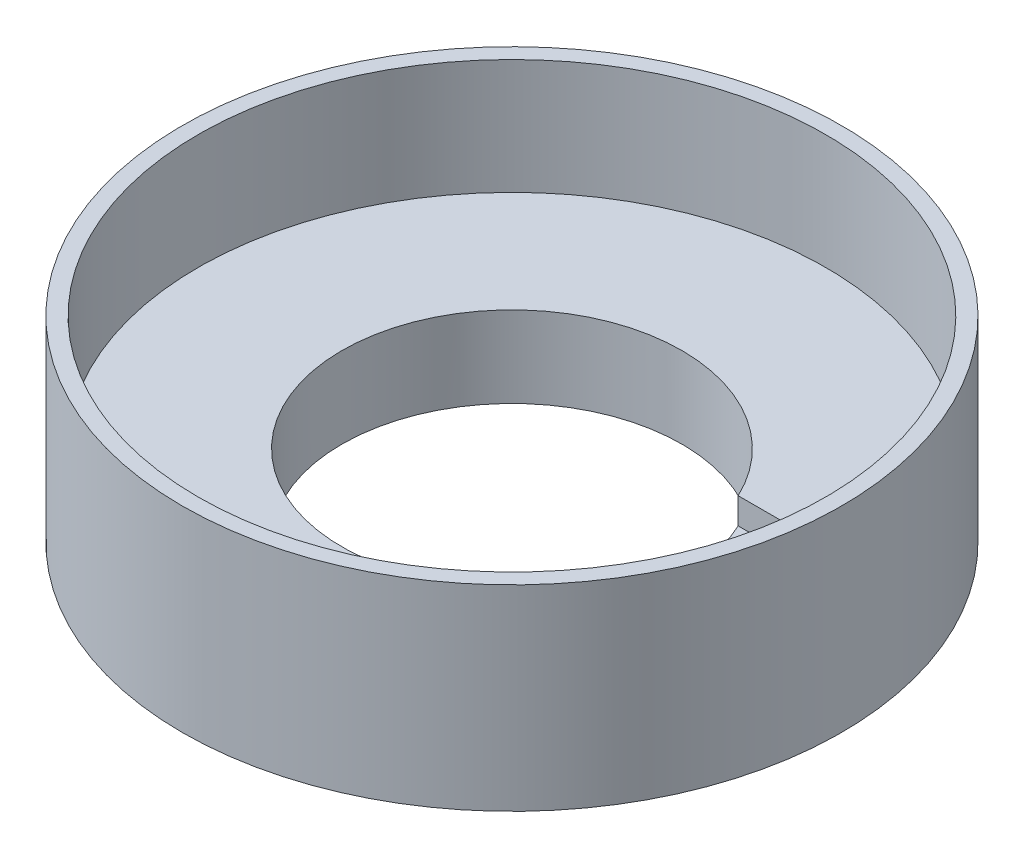
from build123d import *

# Parameters (mm, degrees)
SKETCH4_R           = 63
SKETCH4_R_2         = 32.5
BOSS_EXTRUDE1_DEPTH = 15.5
SKETCH5_R           = 63
SKETCH5_R_2         = 60
BOSS_EXTRUDE2_DEPTH = 22
SKETCH7_W           = 25
SKETCH7_H           = 24.247693635
CUT_EXTRUDE1_DEPTH  = 5


with BuildPart() as part:
    # Sketch4 → Boss-Extrude1 (new body)
    with BuildSketch(Plane(origin=(0, 0, 0), x_dir=(1, 0, 0), z_dir=(0, 1, 0))):
        Circle(SKETCH4_R)
        Circle(SKETCH4_R_2, mode=Mode.SUBTRACT)
    extrude(amount=BOSS_EXTRUDE1_DEPTH)

    # Sketch5 → Boss-Extrude2 (add)
    with BuildSketch(Plane(origin=(0, 15.5, 0), x_dir=(1, 0, 0), z_dir=(0, 1, 0))):
        Circle(SKETCH5_R)
        Circle(SKETCH5_R_2, mode=Mode.SUBTRACT)
    extrude(amount=BOSS_EXTRUDE2_DEPTH)

    # Sketch7 → Cut-Extrude1 (cut)
    with BuildSketch(Plane(origin=(0, 15.5, 0), x_dir=(1, 0, 0), z_dir=(0, 1, 0))):
        with Locations((32.454830069, 1.71289381)):
            Rectangle(SKETCH7_W, SKETCH7_H)
    extrude(amount=-CUT_EXTRUDE1_DEPTH, mode=Mode.SUBTRACT)


solid = part.part
